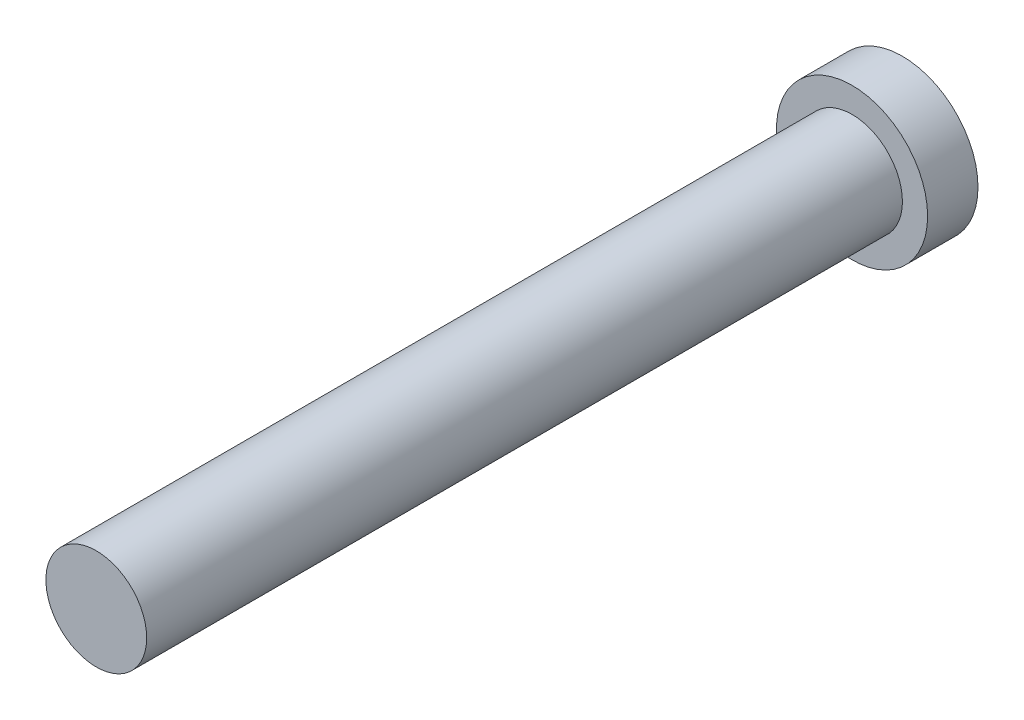
from build123d import *

# Parameters (mm, degrees)
SKETCH1_R           = 3.81
BOSS_EXTRUDE1_DEPTH = 2.54
SKETCH2_R           = 2.54
BOSS_EXTRUDE2_DEPTH = 38.1


with BuildPart() as part:
    # Sketch1 → Boss-Extrude1 (new body)
    with BuildSketch(Plane.XY):
        Circle(SKETCH1_R)
    extrude(amount=BOSS_EXTRUDE1_DEPTH)

    # Sketch2 → Boss-Extrude2 (add)
    with BuildSketch(Plane.XY.offset(2.54)):
        Circle(SKETCH2_R)
    extrude(amount=BOSS_EXTRUDE2_DEPTH)


solid = part.part
